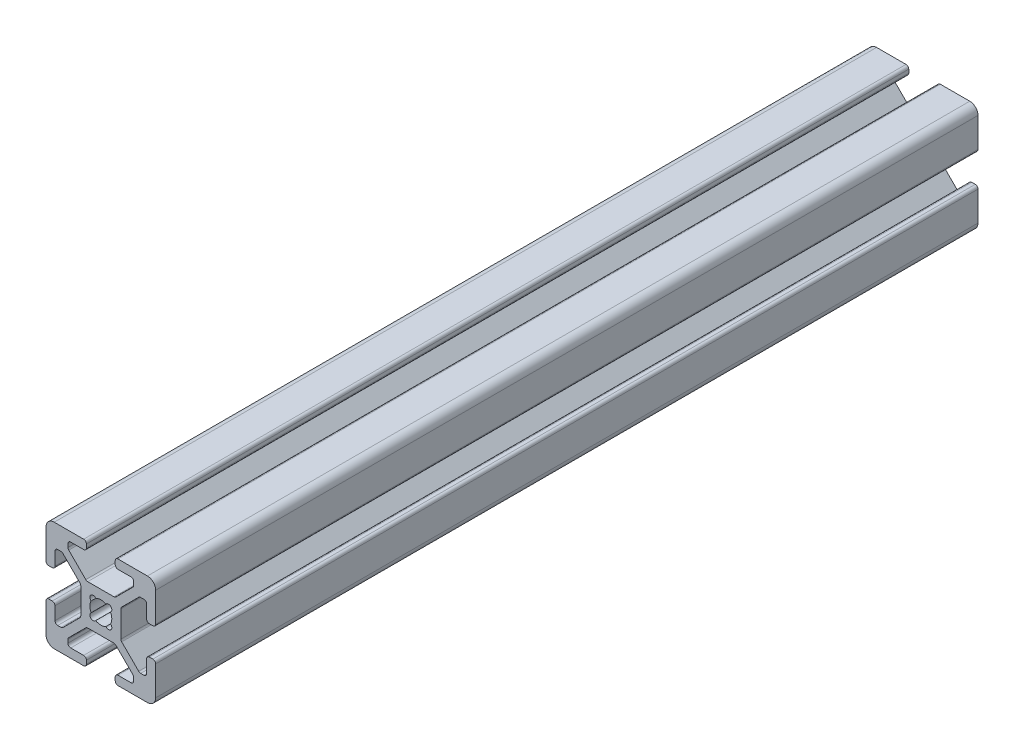
from build123d import *

# Parameters (mm, degrees)
BOSS_EXTRUDE1_DEPTH = 150


with BuildPart() as part:
    # Sketch1 → Boss-Extrude1 (new body)
    with BuildSketch(Plane.XY):
        with BuildLine():
            Line((-2.746356642, -3.807016814), (-5.847983186, -6.908643358))
            ThreePointArc((-5.847983186, -6.908643358), (-5.956791575, -7.07148662), (-5.995, -7.263573344))
            Line((-5.995, -7.263573344), (-5.995, -7.858053199))
            ThreePointArc((-5.995, -7.858053199), (-5.847983186, -8.212983186), (-5.493053199, -8.36))
            Line((-5.493053199, -8.36), (-3.131946801, -8.36))
            ThreePointArc((-3.131946801, -8.36), (-2.777016814, -8.507016814), (-2.63, -8.861946801))
            Line((-2.63, -8.861946801), (-2.63, -9.498053199))
            ThreePointArc((-2.63, -9.498053199), (-2.777016814, -9.852983186), (-3.131946801, -10))
            Line((-3.131946801, -10), (-8.5, -10))
            ThreePointArc((-8.5, -10), (-9.560660172, -9.560660172), (-10, -8.5))
            Line((-10, -8.5), (-10, -3.131946801))
            ThreePointArc((-10, -3.131946801), (-9.852983186, -2.777016814), (-9.498053199, -2.63))
            Line((-9.498053199, -2.63), (-8.861946801, -2.63))
            ThreePointArc((-8.861946801, -2.63), (-8.507016814, -2.777016814), (-8.36, -3.131946801))
            Line((-8.36, -3.131946801), (-8.36, -5.493053199))
            ThreePointArc((-8.36, -5.493053199), (-8.212983186, -5.847983186), (-7.858053199, -5.995))
            Line((-7.858053199, -5.995), (-7.263573344, -5.995))
            ThreePointArc((-7.263573344, -5.995), (-7.07148662, -5.956791575), (-6.908643358, -5.847983186))
            Line((-6.908643358, -5.847983186), (-3.807016814, -2.746356642))
            ThreePointArc((-3.807016814, -2.746356642), (-3.698208425, -2.58351338), (-3.66, -2.391426656))
            Line((-3.66, -2.391426656), (-3.66, 2.391426656))
            ThreePointArc((-3.66, 2.391426656), (-3.698208425, 2.58351338), (-3.807016814, 2.746356642))
            Line((-3.807016814, 2.746356642), (-6.908643358, 5.847983186))
            ThreePointArc((-6.908643358, 5.847983186), (-7.07148662, 5.956791575), (-7.263573344, 5.995))
            Line((-7.263573344, 5.995), (-7.858053199, 5.995))
            ThreePointArc((-7.858053199, 5.995), (-8.212983186, 5.847983186), (-8.36, 5.493053199))
            Line((-8.36, 5.493053199), (-8.36, 3.131946801))
            ThreePointArc((-8.36, 3.131946801), (-8.507016814, 2.777016814), (-8.861946801, 2.63))
            Line((-8.861946801, 2.63), (-9.498053199, 2.63))
            ThreePointArc((-9.498053199, 2.63), (-9.852983186, 2.777016814), (-10, 3.131946801))
            Line((-10, 3.131946801), (-10, 8.5))
            ThreePointArc((-10, 8.5), (-9.560660172, 9.560660172), (-8.5, 10))
            Line((-8.5, 10), (-3.131946801, 10))
            ThreePointArc((-3.131946801, 10), (-2.777016814, 9.852983186), (-2.63, 9.498053199))
            Line((-2.63, 9.498053199), (-2.63, 8.861946801))
            ThreePointArc((-2.63, 8.861946801), (-2.777016814, 8.507016814), (-3.131946801, 8.36))
            Line((-3.131946801, 8.36), (-5.493053199, 8.36))
            ThreePointArc((-5.493053199, 8.36), (-5.847983186, 8.212983186), (-5.995, 7.858053199))
            Line((-5.995, 7.858053199), (-5.995, 7.263573344))
            ThreePointArc((-5.995, 7.263573344), (-5.956791575, 7.07148662), (-5.847983186, 6.908643358))
            Line((-5.847983186, 6.908643358), (-2.746356642, 3.807016814))
            ThreePointArc((-2.746356642, 3.807016814), (-2.58351338, 3.698208425), (-2.391426656, 3.66))
            Line((-2.391426656, 3.66), (2.391426656, 3.66))
            ThreePointArc((2.391426656, 3.66), (2.58351338, 3.698208425), (2.746356642, 3.807016814))
            Line((2.746356642, 3.807016814), (5.847983186, 6.908643358))
            ThreePointArc((5.847983186, 6.908643358), (5.956791575, 7.07148662), (5.995, 7.263573344))
            Line((5.995, 7.263573344), (5.995, 7.858053199))
            ThreePointArc((5.995, 7.858053199), (5.847983186, 8.212983186), (5.493053199, 8.36))
            Line((5.493053199, 8.36), (3.131946801, 8.36))
            ThreePointArc((3.131946801, 8.36), (2.777016814, 8.507016814), (2.63, 8.861946801))
            Line((2.63, 8.861946801), (2.63, 9.498053199))
            ThreePointArc((2.63, 9.498053199), (2.777016814, 9.852983186), (3.131946801, 10))
            Line((3.131946801, 10), (8.5, 10))
            ThreePointArc((8.5, 10), (9.560660172, 9.560660172), (10, 8.5))
            Line((10, 8.5), (10, 3.131946801))
            ThreePointArc((10, 3.131946801), (9.852983186, 2.777016814), (9.498053199, 2.63))
            Line((9.498053199, 2.63), (8.861946801, 2.63))
            ThreePointArc((8.861946801, 2.63), (8.507016814, 2.777016814), (8.36, 3.131946801))
            Line((8.36, 3.131946801), (8.36, 5.493053199))
            ThreePointArc((8.36, 5.493053199), (8.212983186, 5.847983186), (7.858053199, 5.995))
            Line((7.858053199, 5.995), (7.263573344, 5.995))
            ThreePointArc((7.263573344, 5.995), (7.07148662, 5.956791575), (6.908643358, 5.847983186))
            Line((6.908643358, 5.847983186), (3.807016814, 2.746356642))
            ThreePointArc((3.807016814, 2.746356642), (3.698208425, 2.58351338), (3.66, 2.391426656))
            Line((3.66, 2.391426656), (3.66, -2.391426656))
            ThreePointArc((3.66, -2.391426656), (3.698208425, -2.58351338), (3.807016814, -2.746356642))
            Line((3.807016814, -2.746356642), (6.908643358, -5.847983186))
            ThreePointArc((6.908643358, -5.847983186), (7.07148662, -5.956791575), (7.263573344, -5.995))
            Line((7.263573344, -5.995), (7.858053199, -5.995))
            ThreePointArc((7.858053199, -5.995), (8.212983186, -5.847983186), (8.36, -5.493053199))
            Line((8.36, -5.493053199), (8.36, -3.131946801))
            ThreePointArc((8.36, -3.131946801), (8.507016814, -2.777016814), (8.861946801, -2.63))
            Line((8.861946801, -2.63), (9.498053199, -2.63))
            ThreePointArc((9.498053199, -2.63), (9.852983186, -2.777016814), (10, -3.131946801))
            Line((10, -3.131946801), (10, -8.5))
            ThreePointArc((10, -8.5), (9.560660172, -9.560660172), (8.5, -10))
            Line((8.5, -10), (3.131946801, -10))
            ThreePointArc((3.131946801, -10), (2.777016814, -9.852983186), (2.63, -9.498053199))
            Line((2.63, -9.498053199), (2.63, -8.861946801))
            ThreePointArc((2.63, -8.861946801), (2.777016814, -8.507016814), (3.131946801, -8.36))
            Line((3.131946801, -8.36), (5.493053199, -8.36))
            ThreePointArc((5.493053199, -8.36), (5.847983186, -8.212983186), (5.995, -7.858053199))
            Line((5.995, -7.858053199), (5.995, -7.263573344))
            ThreePointArc((5.995, -7.263573344), (5.956791575, -7.07148662), (5.847983186, -6.908643358))
            Line((5.847983186, -6.908643358), (2.746356642, -3.807016814))
            ThreePointArc((2.746356642, -3.807016814), (2.58351338, -3.698208425), (2.391426656, -3.66))
            Line((2.391426656, -3.66), (-2.391426656, -3.66))
            ThreePointArc((-2.391426656, -3.66), (-2.58351338, -3.698208425), (-2.746356642, -3.807016814))
        make_face()
        with BuildLine():
            ThreePointArc((-1.767678053, 0.935582333), (-2, 0), (-1.767678053, -0.935582333))
            ThreePointArc((-1.767678053, -0.935582333), (-1.834942097, -1.834942097), (-0.935582333, -1.767678053))
            ThreePointArc((-0.935582333, -1.767678053), (0, -2), (0.935582333, -1.767678053))
            ThreePointArc((0.935582333, -1.767678053), (1.834942097, -1.834942097), (1.767678053, -0.935582333))
            ThreePointArc((1.767678053, -0.935582333), (2, 0), (1.767678053, 0.935582333))
            ThreePointArc((1.767678053, 0.935582333), (1.834942097, 1.834942097), (0.935582333, 1.767678053))
            ThreePointArc((0.935582333, 1.767678053), (0, 2), (-0.935582333, 1.767678053))
            ThreePointArc((-0.935582333, 1.767678053), (-1.834942097, 1.834942097), (-1.767678053, 0.935582333))
        make_face(mode=Mode.SUBTRACT)
    extrude(amount=BOSS_EXTRUDE1_DEPTH)


solid = part.part
